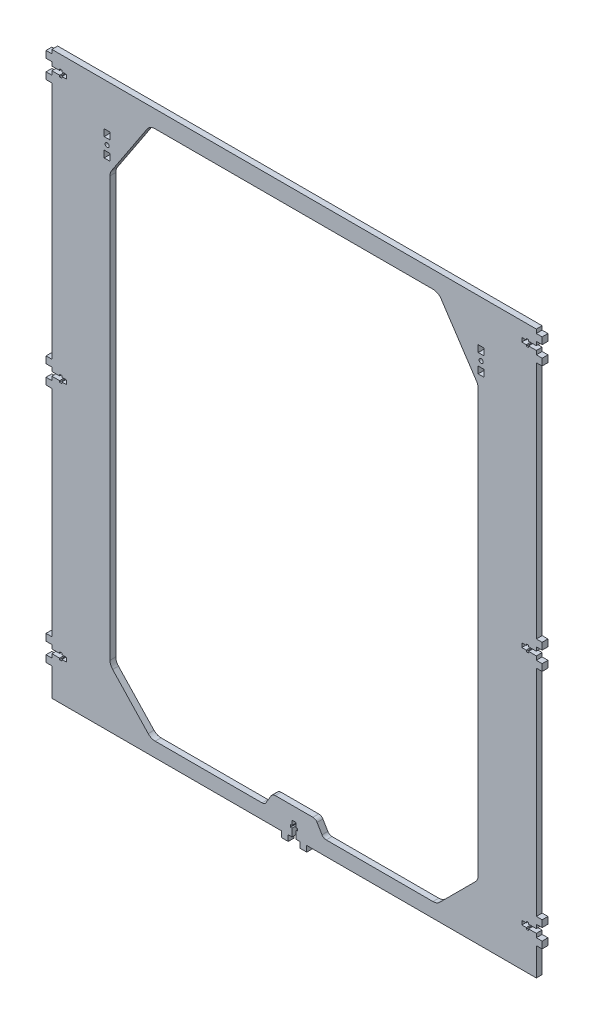
from build123d import *

# Parameters (mm, degrees)
SKETCH_1_W            = 500
SKETCH_1_H            = 580
EXTRUDE_1_DEPTH       = 6
SKETCH_2_W            = 7
SKETCH_2_H            = 6
EXTRUDE_2_DEPTH       = 6
CUT_EXTRUDE_1_DEPTH   = 7
SKETCH_21_W           = 7
SKETCH_21_H           = 6
EXTRUDE_21_DEPTH      = 6
CUT_EXTRUDE_11_DEPTH  = 7
SKETCH_22_W           = 7
SKETCH_22_H           = 6
EXTRUDE_22_DEPTH      = 6
CUT_EXTRUDE_12_DEPTH  = 7
SKETCH_23_W           = 7
SKETCH_23_H           = 6
EXTRUDE_23_DEPTH      = 6
CUT_EXTRUDE_13_DEPTH  = 7
SKETCH_24_W           = 7
SKETCH_24_H           = 6
EXTRUDE_24_DEPTH      = 6
CUT_EXTRUDE_14_DEPTH  = 7
SKETCH_25_W           = 7
SKETCH_25_H           = 6
EXTRUDE_25_DEPTH      = 6
CUT_EXTRUDE_15_DEPTH  = 7
SKETCH_26_W           = 7
SKETCH_26_H           = 6
EXTRUDE_26_DEPTH      = 6
CUT_EXTRUDE_16_DEPTH  = 7
SKETCH_37_R           = 2.1
SKETCH_37_W           = 7
SKETCH_37_H           = 6
CUT_EXTRUDE_17_DEPTH  = 7
SKETCH_311_R          = 2.1
SKETCH_311_W          = 7
SKETCH_311_H          = 6
CUT_EXTRUDE_111_DEPTH = 7


with BuildPart() as part:
    # Эскиз1 → Бобышка-Вытянуть1 (new body)
    with BuildSketch(Plane.XY):
        with Locations((192.327917168, 270.464227839)):
            Rectangle(SKETCH_1_W, SKETCH_1_H)
        with BuildLine():
            Line((2.327917168, 477.456530462), (2.327917168, 44.431098194))
            ThreePointArc((2.327917168, 44.431098194), (3.032569192, 40.743754162), (5.04721837, 37.576069017))
            Line((5.04721837, 37.576069017), (41.735871559, -1.390801337))
            ThreePointArc((41.735871559, -1.390801337), (45.05111274, -3.715921717), (49.016570358, -4.535772161))
            Line((49.016570358, -4.535772161), (159.221052935, -4.535772161))
            ThreePointArc((159.221052935, -4.535772161), (161.686863585, -3.885459257), (163.511254842, -2.103683296))
            Line((163.511254842, -2.103683296), (168.595782425, 6.391022628))
            ThreePointArc((168.595782425, 6.391022628), (170.420173681, 8.172798589), (172.885984332, 8.823111493))
            Line((172.885984332, 8.823111493), (211.769850005, 8.823111493))
            ThreePointArc((211.769850005, 8.823111493), (214.235660655, 8.172798589), (216.060051912, 6.391022628))
            Line((216.060051912, 6.391022628), (221.144579495, -2.103683296))
            ThreePointArc((221.144579495, -2.103683296), (222.968970752, -3.885459257), (225.434781402, -4.535772161))
            Line((225.434781402, -4.535772161), (335.639263979, -4.535772161))
            ThreePointArc((335.639263979, -4.535772161), (339.466098302, -3.774567486), (342.710331791, -1.606839972))
            Line((342.710331791, -1.606839972), (379.39898498, 35.081813217))
            ThreePointArc((379.39898498, 35.081813217), (381.566712493, 38.326046705), (382.327917168, 42.152881029))
            Line((382.327917168, 42.152881029), (382.327917168, 477.456530462))
            ThreePointArc((382.327917168, 477.456530462), (381.904148866, 480.336771158), (380.668759875, 482.972900913))
            Line((380.668759875, 482.972900913), (344.110547273, 538.249518693))
            ThreePointArc((344.110547273, 538.249518693), (340.504485211, 541.541204342), (335.769704567, 542.733148243))
            Line((335.769704567, 542.733148243), (48.88612977, 542.733148243))
            ThreePointArc((48.88612977, 542.733148243), (44.151349126, 541.541204342), (40.545287063, 538.249518693))
            Line((40.545287063, 538.249518693), (3.987074462, 482.972900913))
            ThreePointArc((3.987074462, 482.972900913), (2.75168547, 480.336771158), (2.327917168, 477.456530462))
        make_face(mode=Mode.SUBTRACT)
    extrude(amount=EXTRUDE_1_DEPTH)

    # Эскиз2 → Бобышка-Вытянуть2 (add)
    with BuildSketch(Plane(origin=(192.327917168, 30.464227839, 6), x_dir=(-1, 0, 0), z_dir=(0, 0, 1))):
        with Locations((-9.531849908, 53)):
            Rectangle(SKETCH_2_W, SKETCH_2_H)
        with Locations((9.531849908, 53)):
            Rectangle(SKETCH_2_W, SKETCH_2_H)
    extrude(amount=-EXTRUDE_2_DEPTH)

    # Эскиз3 → Вырез-Вытянуть1 (cut, through all)
    with BuildSketch(Plane(origin=(192.327917168, 30.464227839, 6), x_dir=(-1, 0, 0), z_dir=(0, 0, 1))):
        Polygon((-2.1, 42), (-3.6, 42), (-3.6, 39.6), (-2.1, 39.6), (-2.1, 35), (2.1, 35), (2.1, 39.6), (3.6, 39.6), (3.6, 42), (2.1, 42), (2.1, 50), (-2.1, 50), align=None)
    extrude(amount=-CUT_EXTRUDE_1_DEPTH, mode=Mode.SUBTRACT)

    # Эскиз21 → Бобышка-Вытянуть21 (add)
    with BuildSketch(Plane(origin=(-7.672082832, 543.464227839, 6), x_dir=(0, 1, 0), z_dir=(0, 0, 1))):
        with Locations((-9.531849908, 53)):
            Rectangle(SKETCH_21_W, SKETCH_21_H)
        with Locations((9.531849908, 53)):
            Rectangle(SKETCH_21_W, SKETCH_21_H)
    extrude(amount=-EXTRUDE_21_DEPTH)

    # Эскиз31 → Вырез-Вытянуть11 (cut, through all)
    with BuildSketch(Plane(origin=(-7.672082832, 543.464227839, 6), x_dir=(0, 1, 0), z_dir=(0, 0, 1))):
        Polygon((-2.1, 42), (-3.6, 42), (-3.6, 39.6), (-2.1, 39.6), (-2.1, 35), (2.1, 35), (2.1, 39.6), (3.6, 39.6), (3.6, 42), (2.1, 42), (2.1, 50), (-2.1, 50), align=None)
    extrude(amount=-CUT_EXTRUDE_11_DEPTH, mode=Mode.SUBTRACT)

    # Эскиз22 → Бобышка-Вытянуть22 (add)
    with BuildSketch(Plane(origin=(-7.672082832, 270.464227839, 6), x_dir=(0, 1, 0), z_dir=(0, 0, 1))):
        with Locations((-9.531849908, 53)):
            Rectangle(SKETCH_22_W, SKETCH_22_H)
        with Locations((9.531849908, 53)):
            Rectangle(SKETCH_22_W, SKETCH_22_H)
    extrude(amount=-EXTRUDE_22_DEPTH)

    # Эскиз32 → Вырез-Вытянуть12 (cut, through all)
    with BuildSketch(Plane(origin=(-7.672082832, 270.464227839, 6), x_dir=(0, 1, 0), z_dir=(0, 0, 1))):
        Polygon((-2.1, 42), (-3.6, 42), (-3.6, 39.6), (-2.1, 39.6), (-2.1, 35), (2.1, 35), (2.1, 39.6), (3.6, 39.6), (3.6, 42), (2.1, 42), (2.1, 50), (-2.1, 50), align=None)
    extrude(amount=-CUT_EXTRUDE_12_DEPTH, mode=Mode.SUBTRACT)

    # Эскиз23 → Бобышка-Вытянуть23 (add)
    with BuildSketch(Plane(origin=(392.327917168, 270.464227839, 6), x_dir=(0, -1, 0), z_dir=(0, 0, 1))):
        with Locations((-9.531849908, 53)):
            Rectangle(SKETCH_23_W, SKETCH_23_H)
        with Locations((9.531849908, 53)):
            Rectangle(SKETCH_23_W, SKETCH_23_H)
    extrude(amount=-EXTRUDE_23_DEPTH)

    # Эскиз33 → Вырез-Вытянуть13 (cut, through all)
    with BuildSketch(Plane(origin=(392.327917168, 270.464227839, 6), x_dir=(0, -1, 0), z_dir=(0, 0, 1))):
        Polygon((-2.1, 42), (-3.6, 42), (-3.6, 39.6), (-2.1, 39.6), (-2.1, 35), (2.1, 35), (2.1, 39.6), (3.6, 39.6), (3.6, 42), (2.1, 42), (2.1, 50), (-2.1, 50), align=None)
    extrude(amount=-CUT_EXTRUDE_13_DEPTH, mode=Mode.SUBTRACT)

    # Эскиз24 → Бобышка-Вытянуть24 (add)
    with BuildSketch(Plane(origin=(392.327917168, 22.464227839, 6), x_dir=(0, -1, 0), z_dir=(0, 0, 1))):
        with Locations((-9.531849908, 53)):
            Rectangle(SKETCH_24_W, SKETCH_24_H)
        with Locations((9.531849908, 53)):
            Rectangle(SKETCH_24_W, SKETCH_24_H)
    extrude(amount=-EXTRUDE_24_DEPTH)

    # Эскиз34 → Вырез-Вытянуть14 (cut, through all)
    with BuildSketch(Plane(origin=(392.327917168, 22.464227839, 6), x_dir=(0, -1, 0), z_dir=(0, 0, 1))):
        Polygon((-2.1, 42), (-3.6, 42), (-3.6, 39.6), (-2.1, 39.6), (-2.1, 35), (2.1, 35), (2.1, 39.6), (3.6, 39.6), (3.6, 42), (2.1, 42), (2.1, 50), (-2.1, 50), align=None)
    extrude(amount=-CUT_EXTRUDE_14_DEPTH, mode=Mode.SUBTRACT)

    # Эскиз25 → Бобышка-Вытянуть25 (add)
    with BuildSketch(Plane(origin=(392.327917168, 543.464227839, 6), x_dir=(0, -1, 0), z_dir=(0, 0, 1))):
        with Locations((-9.531849908, 53)):
            Rectangle(SKETCH_25_W, SKETCH_25_H)
        with Locations((9.531849908, 53)):
            Rectangle(SKETCH_25_W, SKETCH_25_H)
    extrude(amount=-EXTRUDE_25_DEPTH)

    # Эскиз35 → Вырез-Вытянуть15 (cut, through all)
    with BuildSketch(Plane(origin=(392.327917168, 543.464227839, 6), x_dir=(0, -1, 0), z_dir=(0, 0, 1))):
        Polygon((-2.1, 42), (-3.6, 42), (-3.6, 39.6), (-2.1, 39.6), (-2.1, 35), (2.1, 35), (2.1, 39.6), (3.6, 39.6), (3.6, 42), (2.1, 42), (2.1, 50), (-2.1, 50), align=None)
    extrude(amount=-CUT_EXTRUDE_15_DEPTH, mode=Mode.SUBTRACT)

    # Эскиз26 → Бобышка-Вытянуть26 (add)
    with BuildSketch(Plane(origin=(-7.672082832, 22.464227839, 6), x_dir=(0, 1, 0), z_dir=(0, 0, 1))):
        with Locations((-9.531849908, 53)):
            Rectangle(SKETCH_26_W, SKETCH_26_H)
        with Locations((9.531849908, 53)):
            Rectangle(SKETCH_26_W, SKETCH_26_H)
    extrude(amount=-EXTRUDE_26_DEPTH)

    # Эскиз36 → Вырез-Вытянуть16 (cut, through all)
    with BuildSketch(Plane(origin=(-7.672082832, 22.464227839, 6), x_dir=(0, 1, 0), z_dir=(0, 0, 1))):
        Polygon((-2.1, 42), (-3.6, 42), (-3.6, 39.6), (-2.1, 39.6), (-2.1, 35), (2.1, 35), (2.1, 39.6), (3.6, 39.6), (3.6, 42), (2.1, 42), (2.1, 50), (-2.1, 50), align=None)
    extrude(amount=-CUT_EXTRUDE_16_DEPTH, mode=Mode.SUBTRACT)

    # Эскиз37 → Вырез-Вытянуть17 (cut, through all)
    with BuildSketch(Plane(origin=(-47.672082832, 503.464227839, 0), x_dir=(0, 1, 0), z_dir=(0, 0, -1))):
        with Locations((0, 47)):
            Circle(SKETCH_37_R)
        with Locations((9.531849908, 47)):
            Rectangle(SKETCH_37_W, SKETCH_37_H)
        with Locations((-9.531849908, 47)):
            Rectangle(SKETCH_37_W, SKETCH_37_H)
    extrude(amount=-CUT_EXTRUDE_17_DEPTH, mode=Mode.SUBTRACT)

    # Эскиз311 → Вырез-Вытянуть111 (cut, through all)
    with BuildSketch(Plane(origin=(432.327917169, 503.464227839, 0), x_dir=(0, -1, 0), z_dir=(0, 0, -1))):
        with Locations((0, 47)):
            Circle(SKETCH_311_R)
        with Locations((9.531849908, 47)):
            Rectangle(SKETCH_311_W, SKETCH_311_H)
        with Locations((-9.531849908, 47)):
            Rectangle(SKETCH_311_W, SKETCH_311_H)
    extrude(amount=-CUT_EXTRUDE_111_DEPTH, mode=Mode.SUBTRACT)


solid = part.part
